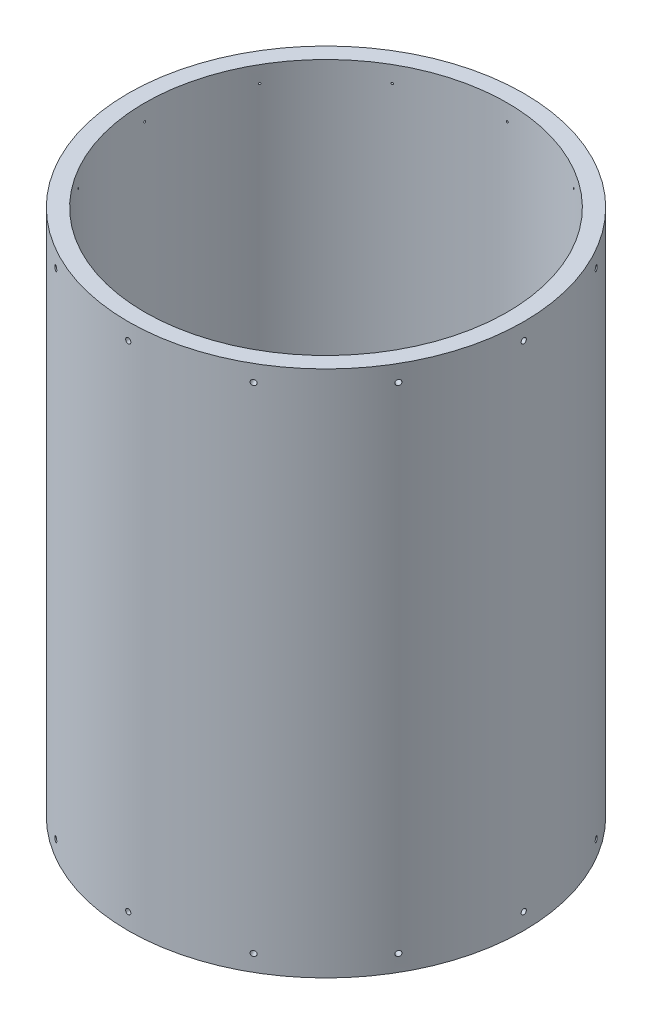
from build123d import *

# Parameters (mm, degrees)
SKETCH1_R           = 152.4
SKETCH1_R_2         = 139.7
BOSS_EXTRUDE1_DEPTH = 406.4
CIRPATTERN1_COUNT   = 12


with BuildPart() as part:
    # Sketch1 → Boss-Extrude1 (new body)
    with BuildSketch(Plane(origin=(0, 0, 0), x_dir=(1, 0, 0), z_dir=(0, 1, 0))):
        Circle(SKETCH1_R)
        Circle(SKETCH1_R_2, mode=Mode.SUBTRACT)
    extrude(amount=BOSS_EXTRUDE1_DEPTH)

    # Sketch3 → #10-32 Tapped Hole1 (revolve, cut)
    with BuildSketch(Plane(origin=(152.4, 393.7, 0), x_dir=(0, 0, -1), z_dir=(0, 1, 0))):
        Polygon((0, 0), (0, 13.151317848), (2.0193, 11.938), (2.0193, 0), align=None)
    f_10_32_tapped_hole1 = revolve(axis=Axis((158.75, 393.7, 0), (-1, 0, 0)), mode=Mode.SUBTRACT)

    # CirPattern1: #10-32 Tapped Hole1 ×12 about axis
    cirpattern1_axis = Axis((0, 406.4, 0), (0, 1, 0))
    for i in range(1, CIRPATTERN1_COUNT):
        add(f_10_32_tapped_hole1.rotate(cirpattern1_axis, i * 360 / CIRPATTERN1_COUNT), mode=Mode.SUBTRACT)

    # Mirror1: #10-32 Tapped Hole1 across plane
    add(f_10_32_tapped_hole1.mirror(Plane.ZX.offset(203.2)), mode=Mode.SUBTRACT)

    # Mirror1 copy 1 sketch → Mirror1 copy 1 (revolve, cut)
    with BuildSketch(Plane(origin=(131.982271537, 12.7, -76.2), x_dir=(-0.5, 0, -0.866025404), z_dir=(0, -1, 0))):
        Polygon((0, 0), (0, -13.151317848), (2.0193, -11.938), (2.0193, 0), align=None)
    revolve(axis=Axis((137.481532851, 12.7, -79.375), (0.866025404, 0, -0.5)), mode=Mode.SUBTRACT)

    # Mirror1 copy 2 sketch → Mirror1 copy 2 (revolve, cut)
    with BuildSketch(Plane(origin=(76.2, 12.7, -131.982271537), x_dir=(-0.866025404, 0, -0.5), z_dir=(0, -1, 0))):
        Polygon((0, 0), (0, -13.151317848), (2.0193, -11.938), (2.0193, 0), align=None)
    revolve(axis=Axis((79.375, 12.7, -137.481532851), (0.5, 0, -0.866025404)), mode=Mode.SUBTRACT)

    # Mirror1 copy 3 sketch → Mirror1 copy 3 (revolve, cut)
    with BuildSketch(Plane(origin=(0, 12.7, -152.4), x_dir=(-1, 0, 0), z_dir=(0, -1, 0))):
        Polygon((0, 0), (0, -13.151317848), (2.0193, -11.938), (2.0193, 0), align=None)
    revolve(axis=Axis((0, 12.7, -158.75), (0, 0, -1)), mode=Mode.SUBTRACT)

    # Mirror1 copy 4 sketch → Mirror1 copy 4 (revolve, cut)
    with BuildSketch(Plane(origin=(-76.2, 12.7, -131.982271537), x_dir=(-0.866025404, 0, 0.5), z_dir=(0, -1, 0))):
        Polygon((0, 0), (0, -13.151317848), (2.0193, -11.938), (2.0193, 0), align=None)
    revolve(axis=Axis((-79.375, 12.7, -137.481532851), (-0.5, 0, -0.866025404)), mode=Mode.SUBTRACT)

    # Mirror1 copy 5 sketch → Mirror1 copy 5 (revolve, cut)
    with BuildSketch(Plane(origin=(-131.982271537, 12.7, -76.2), x_dir=(-0.5, 0, 0.866025404), z_dir=(0, -1, 0))):
        Polygon((0, 0), (0, -13.151317848), (2.0193, -11.938), (2.0193, 0), align=None)
    revolve(axis=Axis((-137.481532851, 12.7, -79.375), (-0.866025404, 0, -0.5)), mode=Mode.SUBTRACT)

    # Mirror1 copy 6 sketch → Mirror1 copy 6 (revolve, cut)
    with BuildSketch(Plane(origin=(-152.4, 12.7, 0), x_dir=(0, 0, 1), z_dir=(0, -1, 0))):
        Polygon((0, 0), (0, -13.151317848), (2.0193, -11.938), (2.0193, 0), align=None)
    revolve(axis=Axis((-158.75, 12.7, 0), (-1, 0, 0)), mode=Mode.SUBTRACT)

    # Mirror1 copy 7 sketch → Mirror1 copy 7 (revolve, cut)
    with BuildSketch(Plane(origin=(-131.982271537, 12.7, 76.2), x_dir=(0.5, 0, 0.866025404), z_dir=(0, -1, 0))):
        Polygon((0, 0), (0, -13.151317848), (2.0193, -11.938), (2.0193, 0), align=None)
    revolve(axis=Axis((-137.481532851, 12.7, 79.375), (-0.866025404, 0, 0.5)), mode=Mode.SUBTRACT)

    # Mirror1 copy 8 sketch → Mirror1 copy 8 (revolve, cut)
    with BuildSketch(Plane(origin=(-76.2, 12.7, 131.982271537), x_dir=(0.866025404, 0, 0.5), z_dir=(0, -1, 0))):
        Polygon((0, 0), (0, -13.151317848), (2.0193, -11.938), (2.0193, 0), align=None)
    revolve(axis=Axis((-79.375, 12.7, 137.481532851), (-0.5, 0, 0.866025404)), mode=Mode.SUBTRACT)

    # Mirror1 copy 9 sketch → Mirror1 copy 9 (revolve, cut)
    with BuildSketch(Plane(origin=(0, 12.7, 152.4), x_dir=(1, 0, 0), z_dir=(0, -1, 0))):
        Polygon((0, 0), (0, -13.151317848), (2.0193, -11.938), (2.0193, 0), align=None)
    revolve(axis=Axis((0, 12.7, 158.75), (0, 0, 1)), mode=Mode.SUBTRACT)

    # Mirror1 copy 10 sketch → Mirror1 copy 10 (revolve, cut)
    with BuildSketch(Plane(origin=(76.2, 12.7, 131.982271537), x_dir=(0.866025404, 0, -0.5), z_dir=(0, -1, 0))):
        Polygon((0, 0), (0, -13.151317848), (2.0193, -11.938), (2.0193, 0), align=None)
    revolve(axis=Axis((79.375, 12.7, 137.481532851), (0.5, 0, 0.866025404)), mode=Mode.SUBTRACT)

    # Mirror1 copy 11 sketch → Mirror1 copy 11 (revolve, cut)
    with BuildSketch(Plane(origin=(131.982271537, 12.7, 76.2), x_dir=(0.5, 0, -0.866025404), z_dir=(0, -1, 0))):
        Polygon((0, 0), (0, -13.151317848), (2.0193, -11.938), (2.0193, 0), align=None)
    revolve(axis=Axis((137.481532851, 12.7, 79.375), (0.866025404, 0, 0.5)), mode=Mode.SUBTRACT)


solid = part.part
